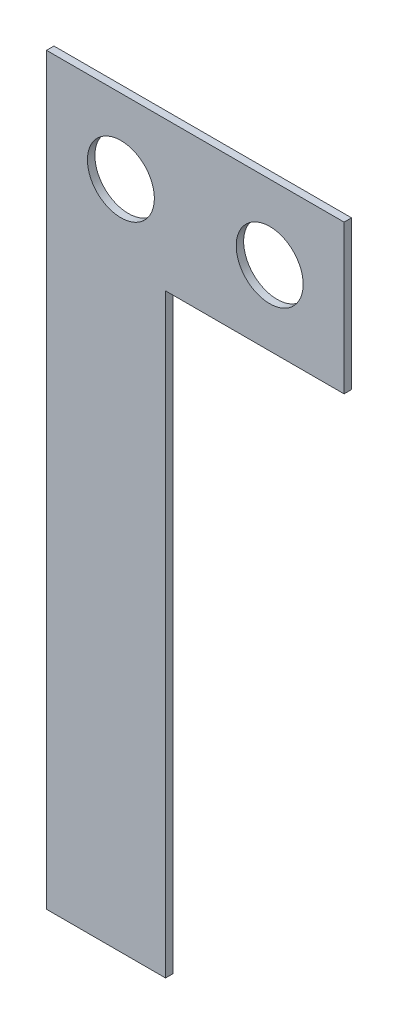
from build123d import *

# Parameters (mm, degrees)
ESQUISSE1_R          = 1.25
BOSS_EXTRU_1_DEPTH   = 0.5
D_GAGEMENT_M41_D     = 4.5
D_GAGEMENT_M41_DEPTH = 16


with BuildPart() as part:
    # Esquisse1 → Boss.-Extru.1 (new body)
    with BuildSketch(Plane.XY):
        Polygon((0, 0), (0, -50), (8, -50), (8, -10), (20, -10), (20, 0), align=None)
        with Locations((15, -5)):
            Circle(ESQUISSE1_R, mode=Mode.SUBTRACT)
        with Locations((5, -5)):
            Circle(ESQUISSE1_R, mode=Mode.SUBTRACT)
    extrude(amount=BOSS_EXTRU_1_DEPTH)

    # Dégagement M41
    with Locations(Plane.XY.offset(0.5)):
        with Locations((5, -5), (15, -5)):
            Hole(D_GAGEMENT_M41_D / 2, depth=D_GAGEMENT_M41_DEPTH)


solid = part.part
